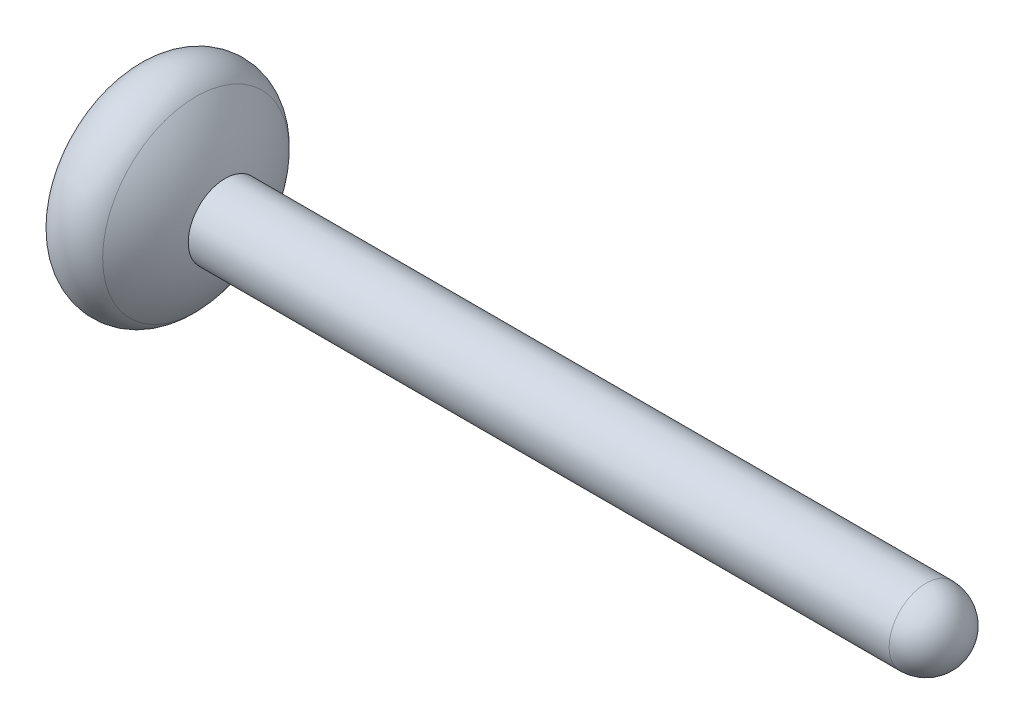
from build123d import *

# Parameters (mm, degrees)
FILLET_1_R = 0.5


with BuildPart() as part:
    # 草图1 → 旋转2 (revolve)
    with BuildSketch(Plane.XY):
        with BuildLine():
            Line((1.9, 0.5), (11.9, 0.5))
            Line((11.9, 0.5), (11.9, 0))
            Line((11.9, 0), (4, 0))
            Line((4, 0), (3.266776521, 0))
            Line((3.266776521, 0), (1.729753624, 0))
            Line((1.729753624, 0), (1.2, 0))
            ThreePointArc((1.2, 0), (1.172400412, 0.255885273), (1.090871211, 0.5))
            ThreePointArc((1.090871211, 0.5), (0.887385904, 0.807803353), (0.6, 1.039230485))
            Line((0.6, 1.039230485), (0.982344135, 1.701469953))
            ThreePointArc((0.982344135, 1.701469953), (1.561364608, 1.192535349), (1.9, 0.5))
        make_face()
    revolve(axis=Axis((0, 0, 0), (1, 0, 0)))

    # 圆角1
    fillet_1_edges = [part.edges().sort_by_distance(p)[0] for p in [
        (11.9, -0.5, 0),
        (0.982344135, -1.701469953, 0),
    ]]
    fillet(fillet_1_edges, radius=FILLET_1_R)


solid = part.part
